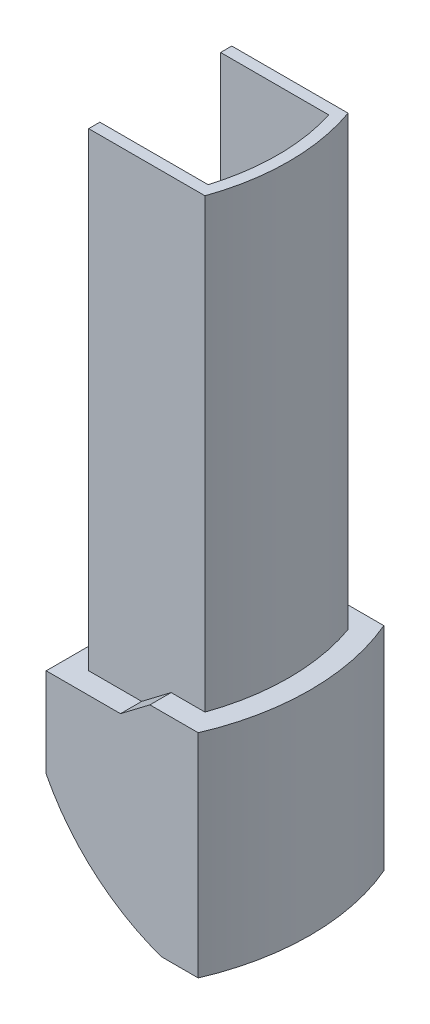
from build123d import *

# Parameters (mm, degrees)
BOSS_EXTRUDE1_DEPTH      = 16.6
CUT_EXTRUDE1_DEPTH       = 20
BOSS_EXTRUDE2_DEPTH      = 30
BOSS_EXTRUDE2_DEPTH_BACK = 16.6


with BuildPart() as part:
    # Sketch1 → Boss-Extrude1 (new body)
    with BuildSketch(Plane.XY):
        with BuildLine():
            Line((0, 0), (-5, 0))
            ThreePointArc((-5, 0), (-11.010326512, 3.515404103), (-15.3, 9))
            Line((-15.3, 9), (-15.3, 17))
            Line((-15.3, 17), (-8.655870189, 17))
            Line((-8.655870189, 17), (-6.022263631, 19))
            Line((-6.022263631, 19), (0, 19))
            Line((0, 19), (0, 0))
        make_face()
    extrude(amount=BOSS_EXTRUDE1_DEPTH)

    # Sketch2 → Cut-Extrude1 (cut, through all)
    with BuildSketch(Plane.XZ):
        with BuildLine():
            Line((0, 16.6), (-1.7, 16.6))
            ThreePointArc((-1.7, 16.6), (-0.429366175, 12.536153916), (0, 8.3))
            Line((0, 8.3), (0, 16.6))
        make_face()
        with BuildLine():
            Line((0, 0), (0, 8.3))
            ThreePointArc((0, 8.3), (-0.429366175, 4.063846084), (-1.7, 0))
            Line((-1.7, 0), (0, 0))
        make_face()
    extrude(amount=-CUT_EXTRUDE1_DEPTH, mode=Mode.SUBTRACT)

    # Sketch3 → Boss-Extrude2 (add, two sides)
    with BuildSketch(Plane(origin=(0, 29, 0), x_dir=(1, 0, 0), z_dir=(0, 1, 0))) as boss_extrude2_sk:
        with BuildLine():
            Line((-13.4, -1.9), (-2.99735323, -1.9))
            ThreePointArc((-2.99735323, -1.9), (-1.9, -8.3), (-2.99735323, -14.7))
            Line((-2.99735323, -14.7), (-13.4, -14.7))
            Line((-13.4, -14.7), (-13.4, -13.7))
            Line((-13.4, -13.7), (-12.4, -13.7))
            Line((-12.4, -13.7), (-3.71899685, -13.7))
            ThreePointArc((-3.71899685, -13.7), (-2.9, -8.3), (-3.71899685, -2.9))
            Line((-3.71899685, -2.9), (-12.4, -2.9))
            Line((-12.4, -2.9), (-13.4, -2.9))
            Line((-13.4, -2.9), (-13.4, -1.9))
        make_face()
    extrude(amount=BOSS_EXTRUDE2_DEPTH)
    extrude(boss_extrude2_sk.sketch, amount=-BOSS_EXTRUDE2_DEPTH_BACK)


solid = part.part
